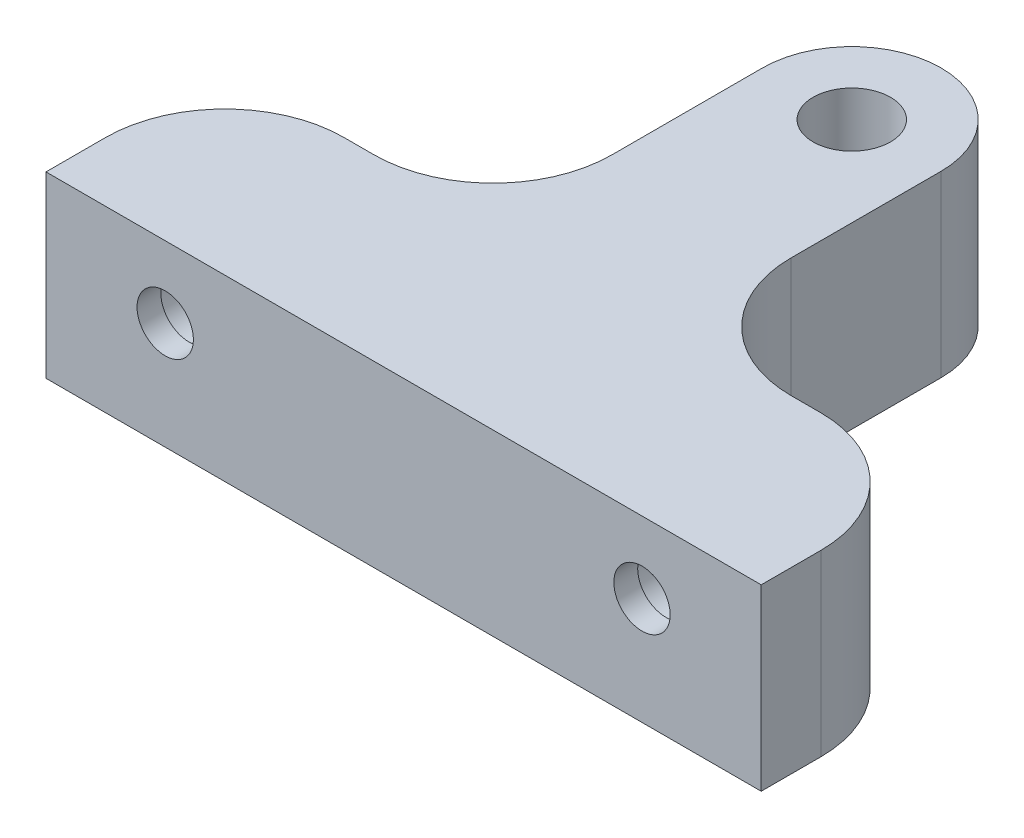
from build123d import *

# Parameters (mm, degrees)
SKETCH1_R               = 4.125
BOSS_EXTRUDE1_DEPTH     = 19.05
SKETCH2_R               = 3
CUT_EXTRUDE1_DEPTH      = 19.05
CUT_EXTRUDE2_DEPTH      = 16.51
CUT_EXTRUDE2_DEPTH_BACK = 16.51
SKETCH3_R               = 3.44


with BuildPart() as part:
    # Sketch1 → Boss-Extrude1 (new body)
    with BuildSketch(Plane(origin=(0, 0, 0), x_dir=(1, 0, 0), z_dir=(0, 1, 0))):
        with BuildLine():
            Line((0, 6.35), (0, 0))
            Line((0, 0), (41.275, 0))
            Line((41.275, 0), (60.325, 0))
            Line((60.325, 0), (76.2, 0))
            Line((76.2, 0), (76.2, 6.35))
            ThreePointArc((76.2, 6.35), (72.480256121, 15.330256121), (63.5, 19.05))
            Line((63.5, 19.05), (60.325, 19.05))
            ThreePointArc((60.325, 19.05), (51.344743879, 22.769743879), (47.625, 31.75))
            Line((47.625, 31.75), (47.625, 47.752))
            ThreePointArc((47.625, 47.752), (38.1, 57.277), (28.575, 47.752))
            Line((28.575, 47.752), (28.575, 31.75))
            ThreePointArc((28.575, 31.75), (24.855256121, 22.769743879), (15.875, 19.05))
            Line((15.875, 19.05), (12.7, 19.05))
            ThreePointArc((12.7, 19.05), (3.719743879, 15.330256121), (0, 6.35))
        make_face()
        with Locations((38.1, 47.752)):
            Circle(SKETCH1_R, mode=Mode.SUBTRACT)
    extrude(amount=-BOSS_EXTRUDE1_DEPTH)

    # Sketch2 → Cut-Extrude1 (cut)
    with BuildSketch(Plane(origin=(0, 0, -19.05), x_dir=(-1, 0, 0), z_dir=(0, 0, -1))):
        with Locations((-63.5, -7.62)):
            Circle(SKETCH2_R)
        with Locations((-12.7, -7.62)):
            Circle(SKETCH2_R)
    extrude(amount=-CUT_EXTRUDE1_DEPTH, mode=Mode.SUBTRACT)

    # Sketch3 → Cut-Extrude2 (cut, two sides: drawn at the far end of the back side and taken through both)
    with BuildSketch(Plane(origin=(0, 0, -19.05), x_dir=(-1, 0, 0), z_dir=(0, 0, -1)).offset(-CUT_EXTRUDE2_DEPTH_BACK)):
        with Locations((-63.5, -7.62)):
            Circle(SKETCH3_R)
        with Locations((-12.7, -7.62)):
            Circle(SKETCH3_R)
    extrude(amount=CUT_EXTRUDE2_DEPTH + CUT_EXTRUDE2_DEPTH_BACK, mode=Mode.SUBTRACT)


solid = part.part
